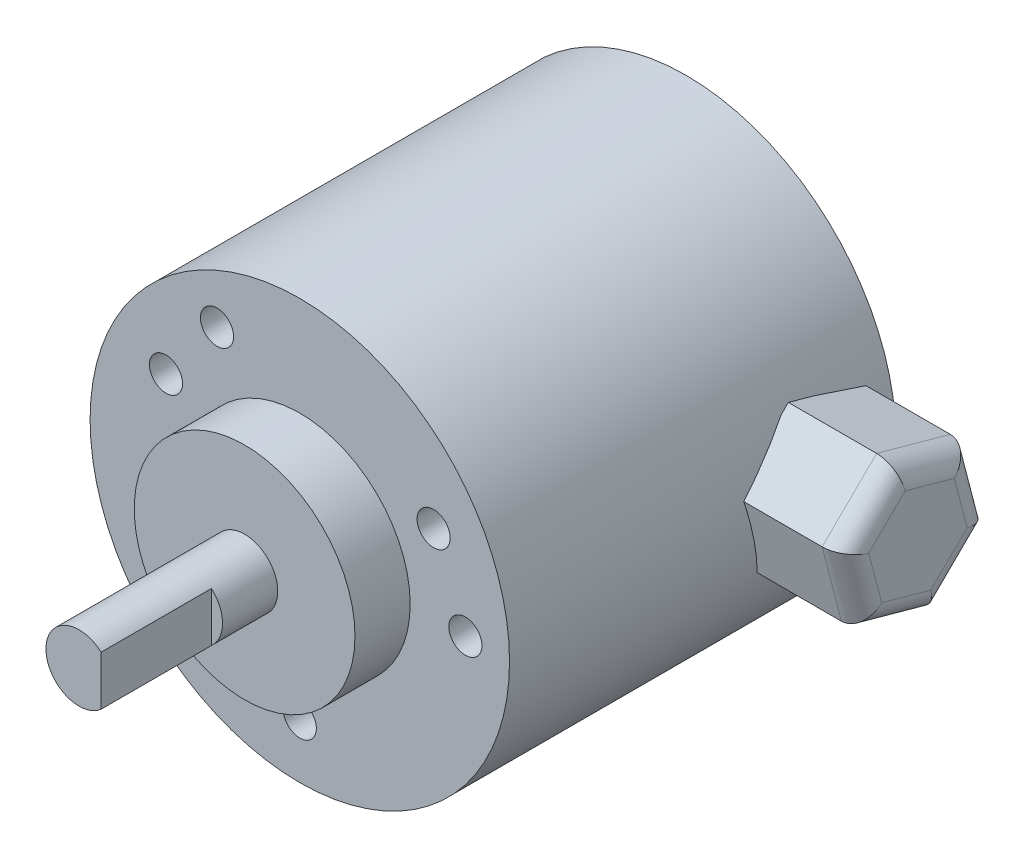
from build123d import *

# Parameters (mm, degrees)
SKETCH3_R                = 19
BOSS_EXTRUDE1_DEPTH      = 40
SKETCH4_R                = 19
SKETCH4_R_2              = 10
CUT_EXTRUDE1_DEPTH       = 5
SKETCH6_R                = 1.5
CUT_EXTRUDE2_DEPTH       = 6.6
SKETCH5_R                = 3
BOSS_EXTRUDE2_DEPTH      = 15
BOSS_EXTRUDE3_DEPTH      = 9
BOSS_EXTRUDE3_DEPTH_BACK = 1
FILLET1_R                = 2
CUT_EXTRUDE3_DEPTH       = 10


with BuildPart() as part:
    # Sketch3 → Boss-Extrude1 (new body)
    with BuildSketch(Plane.XY):
        Circle(SKETCH3_R)
    extrude(amount=BOSS_EXTRUDE1_DEPTH)

    # Sketch4 → Cut-Extrude1 (cut)
    with BuildSketch(Plane.XY.offset(40)):
        Circle(SKETCH4_R)
        Circle(SKETCH4_R_2, mode=Mode.SUBTRACT)
    extrude(amount=-CUT_EXTRUDE1_DEPTH, mode=Mode.SUBTRACT)

    # Sketch6 → Cut-Extrude2 (cut)
    with BuildSketch(Plane.XY.offset(35)):
        with Locations((15, 0)):
            Circle(SKETCH6_R)
        with Locations((-7.5, -12.990381057)):
            Circle(SKETCH6_R)
        with Locations((-7.5, 12.990381057)):
            Circle(SKETCH6_R)
        with Locations((12.124355653, 7)):
            Circle(SKETCH6_R)
        with Locations((-12.124355653, 7)):
            Circle(SKETCH6_R)
        with Locations((0, -14)):
            Circle(SKETCH6_R)
    extrude(amount=-CUT_EXTRUDE2_DEPTH, mode=Mode.SUBTRACT)

    # Sketch5 → Boss-Extrude2 (add)
    with BuildSketch(Plane.XY.offset(40)):
        Circle(SKETCH5_R)
    extrude(amount=BOSS_EXTRUDE2_DEPTH)

    # Sketch9 → Cut-Extrude3 (cut)
    with BuildSketch(Plane.XY.offset(55)):
        with BuildLine():
            Line((2, 2.236067977), (2, -2.236067977))
            ThreePointArc((2, -2.236067977), (3, 0), (2, 2.236067977))
        make_face()
    extrude(amount=-CUT_EXTRUDE3_DEPTH, mode=Mode.SUBTRACT)


with BuildPart() as body_2:
    # Sketch8 → Boss-Extrude3 (new body, two sides)
    with BuildSketch(Plane(origin=(19, 0, 0), x_dir=(0, 0, -1), z_dir=(1, 0, 0))) as boss_extrude3_sk:
        Polygon((-2.063552027, 4.861222214), (-8.741717944, 6.705700456), (-13.678165917, 1.844478242), (-11.936447973, -4.861222214), (-5.258282056, -6.705700456), (-0.321834083, -1.844478242), align=None)
    extrude(amount=BOSS_EXTRUDE3_DEPTH)
    extrude(boss_extrude3_sk.sketch, amount=-BOSS_EXTRUDE3_DEPTH_BACK)

    # Fillet1
    fillet1_edges = [body_2.edges().sort_by_distance(p)[0] for p in [
        (28, 1.508371986, 1.192693055),
        (28, 5.783461335, 5.402634986),
        (28, 4.275089349, 11.209941931),
        (28, -1.508371986, 12.807306945),
        (28, -5.783461335, 8.597365014),
        (28, -4.275089349, 2.790058069),
    ]]
    fillet(fillet1_edges, radius=FILLET1_R)


solid = Compound([part.part, body_2.part])
